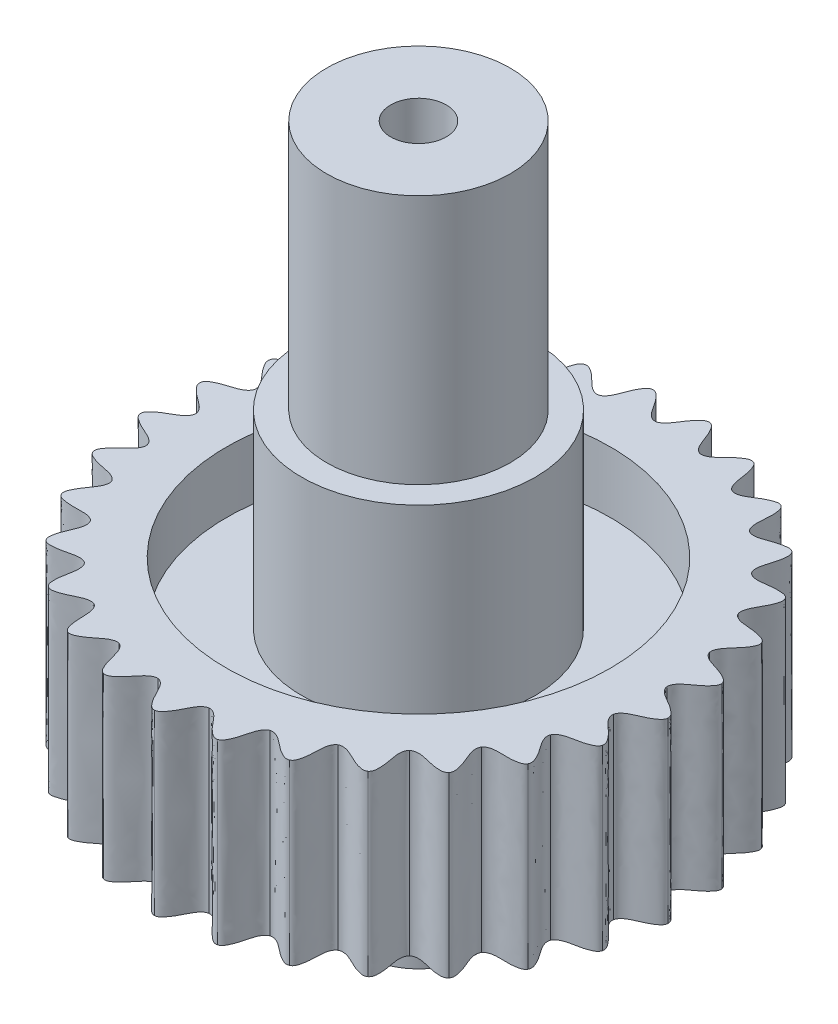
from build123d import *

# Parameters (mm, degrees)
SKETCH2_R           = 1
CUT_EXTRUDE1_DEPTH  = 26.777897509
BOSS_EXTRUDE1_START = 3
BOSS_EXTRUDE1_DEPTH = 3
CUT_EXTRUDE2_DEPTH  = 25.093567606
CIRPATTERN1_COUNT   = 29


with BuildPart() as part:
    # Sketch1 → Revolve1 (revolve)
    with BuildSketch(Plane.XY):
        Polygon((-9.5, 0), (-9.5, 6.4), (-6.9, 6.4), (-6.9, 4.2), (-4.2, 4.2), (-4.2, 11), (-3.3, 11), (-3.3, 20), (0, 20), (0, -2), (-3.25, -2), (-3.25, 2.7), (-6.9, 2.7), (-6.9, 0), align=None)
    revolve(axis=Axis((0, -2, 0), (0, 1, 0)))

    # Sketch2 → Cut-Extrude1 (cut, through all)
    with BuildSketch(Plane.XZ.offset(2)):
        Circle(SKETCH2_R)
    extrude(amount=-CUT_EXTRUDE1_DEPTH, mode=Mode.SUBTRACT)

    # Sketch3 → Boss-Extrude1 (add)
    with BuildSketch(Plane.XZ.offset(2).offset(BOSS_EXTRUDE1_START)):
        with BuildLine():
            Line((-0.866025404, -0.5), (-1.732050808, -1))
            ThreePointArc((-1.732050808, -1), (0, 2), (1.732050808, -1))
            Line((1.732050808, -1), (0.866025404, -0.5))
            ThreePointArc((0.866025404, -0.5), (0, 1), (-0.866025404, -0.5))
        make_face()
    extrude(amount=-BOSS_EXTRUDE1_DEPTH)

    # Sketch4 → Cut-Extrude2 (cut, through all)
    with BuildSketch(Plane.XZ):
        with BuildLine():
            ThreePointArc((0, 9.5), (1.027130675, 9.444310593), (2.042219182, 9.277895279))
            add(Edge.make_bspline(
                [(2.042219182, 9.277895279), (1.935653168, 9.301352233), (1.71793844, 9.149158345), (1.447208583, 8.858415748), (1.219289713, 8.530791835), (0.987593535, 8.442713907), (0.919011657, 8.450172636)],
                knots=[0, 0, 0, 0, 0.209176706, 0.494424311, 0.866884916, 1, 1, 1, 1], degree=3))
            add(Edge.make_bspline(
                [(0, 9.5), (0.109117112, 9.5), (0.289024603, 9.30456209), (0.490923882, 8.962417977), (0.643084679, 8.593457909), (0.850429778, 8.457631365), (0.919011657, 8.450172636)],
                knots=[0, 0, 0, 0, 0.209176706, 0.494424311, 0.866884916, 1, 1, 1, 1], degree=3))
        make_face()
    cut_extrude2 = extrude(amount=-CUT_EXTRUDE2_DEPTH, mode=Mode.SUBTRACT)

    # CirPattern1: Cut-Extrude2 ×29 about axis
    cirpattern1_axis = Axis((0, 20, 0), (0, -1, 0))
    for i in range(1, CIRPATTERN1_COUNT):
        add(cut_extrude2.rotate(cirpattern1_axis, i * 360 / CIRPATTERN1_COUNT), mode=Mode.SUBTRACT)


solid = part.part
